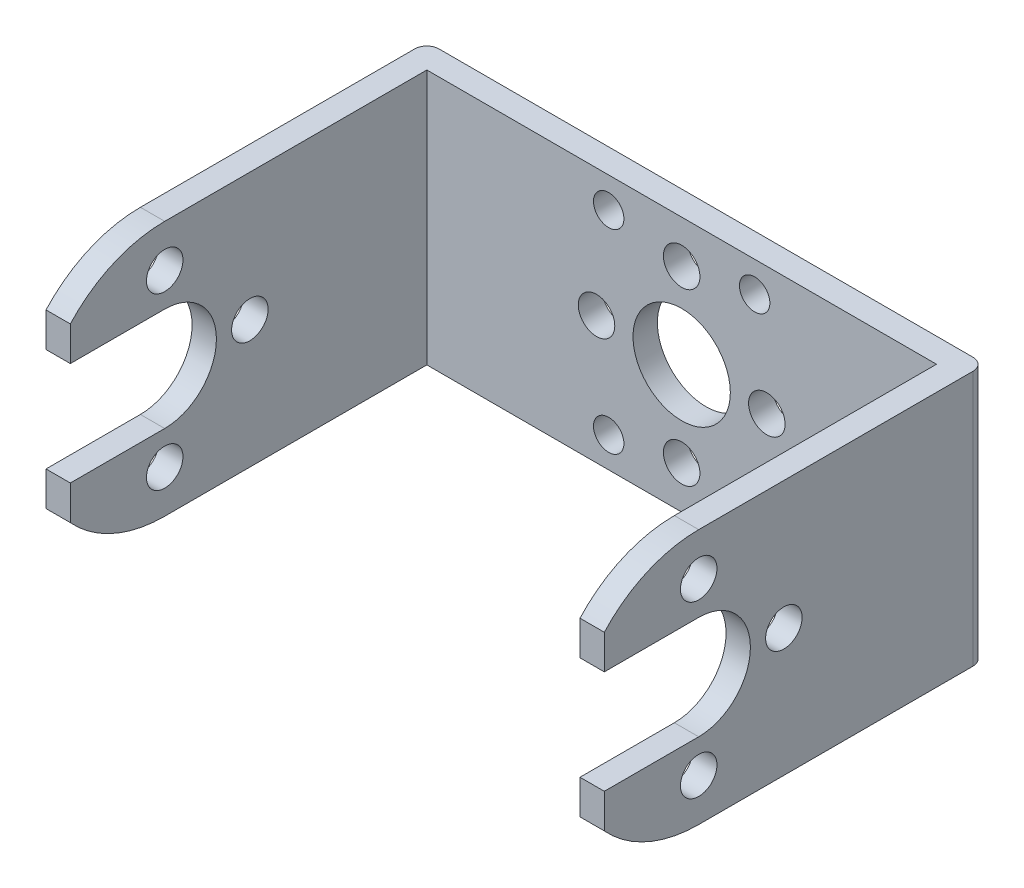
from build123d import *

# Parameters (mm, degrees)
SKETCH1_W           = 41.9
SKETCH1_H           = 21
SKETCH1_R           = 1.25
SKETCH1_R_2         = 1.5
SKETCH1_R_3         = 4
BOSS_EXTRUDE1_DEPTH = 2
SKETCH1_3_W         = 2
SKETCH1_3_H         = 21
BOSS_EXTRUDE2_DEPTH = 31.31
SKETCH2_R           = 1.5
CUT_EXTRUDE1_DEPTH  = 50
FILLET1_R           = 1


with BuildPart() as part:
    # Sketch1 → Boss-Extrude1 (new body)
    with BuildSketch(Plane.XY):
        Rectangle(SKETCH1_W, SKETCH1_H)
        with Locations((-6, 8)):
            Circle(SKETCH1_R, mode=Mode.SUBTRACT)
        with Locations((-7, 0)):
            Circle(SKETCH1_R_2, mode=Mode.SUBTRACT)
        with Locations((-6, -8)):
            Circle(SKETCH1_R, mode=Mode.SUBTRACT)
        with Locations((0, -7)):
            Circle(SKETCH1_R_2, mode=Mode.SUBTRACT)
        with Locations((6, -8)):
            Circle(SKETCH1_R, mode=Mode.SUBTRACT)
        with Locations((7, 0)):
            Circle(SKETCH1_R_2, mode=Mode.SUBTRACT)
        with Locations((6, 8)):
            Circle(SKETCH1_R, mode=Mode.SUBTRACT)
        with Locations((0, 7)):
            Circle(SKETCH1_R_2, mode=Mode.SUBTRACT)
        Circle(SKETCH1_R_3, mode=Mode.SUBTRACT)
    extrude(amount=BOSS_EXTRUDE1_DEPTH)

    # Sketch1_3 → Boss-Extrude2 (add)
    with BuildSketch(Plane.XY):
        with Locations((-21.95, 0)):
            Rectangle(SKETCH1_3_W, SKETCH1_3_H)
        with Locations((21.95, 0)):
            Rectangle(SKETCH1_3_W, SKETCH1_3_H)
    extrude(amount=BOSS_EXTRUDE2_DEPTH)

    # Sketch2 → Cut-Extrude1 (cut)
    with BuildSketch(Plane.ZY.offset(22.95)):
        with Locations((16.55, 0)):
            Circle(SKETCH2_R)
        with BuildLine():
            Line((31.31, 10.5), (23.55, 10.5))
            ThreePointArc((23.55, 10.5), (27.791446457, 9.60521379), (31.31, 7.073358467))
            Line((31.31, 7.073358467), (31.31, 10.5))
        make_face()
        with BuildLine():
            ThreePointArc((31.31, -7.073358467), (27.791446457, -9.60521379), (23.55, -10.5))
            Line((23.55, -10.5), (31.31, -10.5))
            Line((31.31, -10.5), (31.31, -7.073358467))
        make_face()
        with Locations((23.55, 7)):
            Circle(SKETCH2_R)
        with Locations((23.55, -7)):
            Circle(SKETCH2_R)
        with BuildLine():
            Line((31.31, -4.25), (31.31, 4.25))
            Line((31.31, 4.25), (23.55, 4.25))
            ThreePointArc((23.55, 4.25), (19.3, 0), (23.55, -4.25))
            Line((23.55, -4.25), (31.31, -4.25))
        make_face()
    extrude(amount=-CUT_EXTRUDE1_DEPTH, mode=Mode.SUBTRACT)

    # Fillet1
    fillet1_edges = [part.edges().sort_by_distance(p)[0] for p in [
        (22.95, 0, 0),
        (-22.95, 0, 0),
    ]]
    fillet(fillet1_edges, radius=FILLET1_R)


solid = part.part
